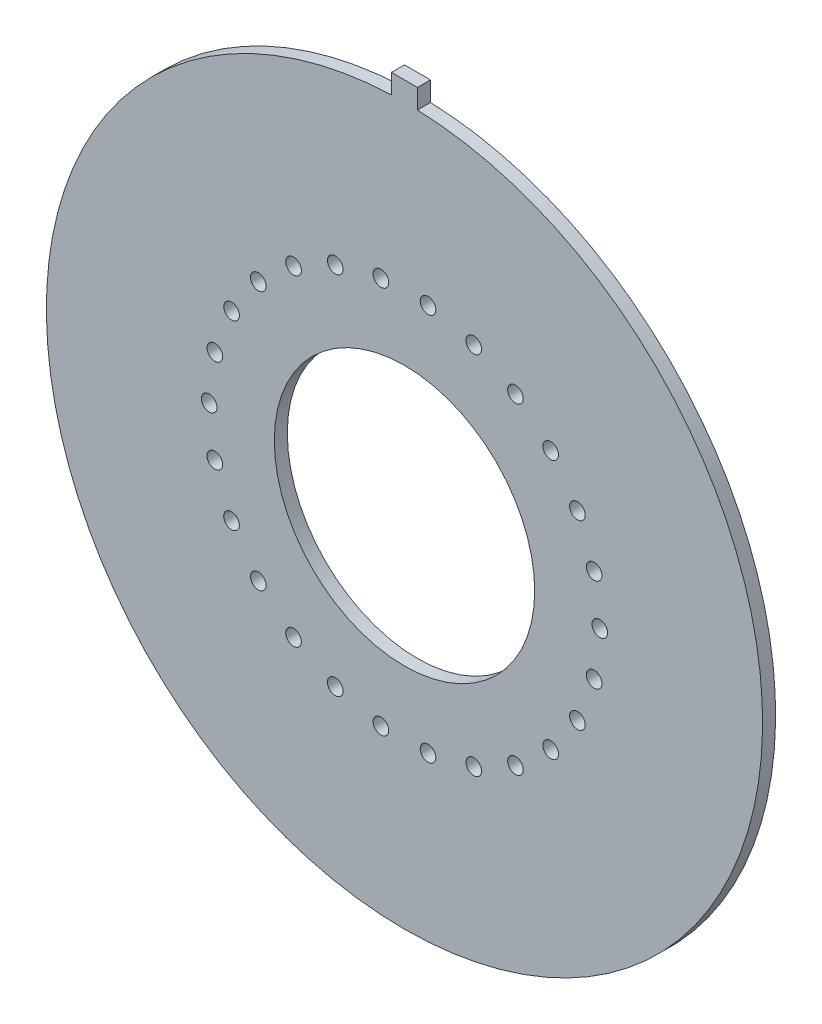
from build123d import *

# Parameters (mm, degrees)
PCB_DIMENSION_R     = 0.6
PCB_DIMENSION_R_2   = 10
BOSS_EXTRUDE1_DEPTH = 1


with BuildPart() as part:
    # PCB dimension → Boss-Extrude1 (new body)
    with BuildSketch(Plane.XY):
        with BuildLine():
            Line((-1, 27.481812167), (-1, 28.981812167))
            Line((-1, 28.981812167), (1, 28.981812167))
            Line((1, 28.981812167), (1, 27.481812167))
            ThreePointArc((1, 27.481812167), (0, -27.5), (-1, 27.481812167))
        make_face()
        with Locations((15, 0)):
            Circle(PCB_DIMENSION_R, mode=Mode.SUBTRACT)
        with Locations((14.564127261, -3.589734964)):
            Circle(PCB_DIMENSION_R, mode=Mode.SUBTRACT)
        with Locations((13.281840385, -6.970847581)):
            Circle(PCB_DIMENSION_R, mode=Mode.SUBTRACT)
        with Locations((11.227661223, -9.946839874)):
            Circle(PCB_DIMENSION_R, mode=Mode.SUBTRACT)
        with Locations((8.520971201, -12.344757988)):
            Circle(PCB_DIMENSION_R, mode=Mode.SUBTRACT)
        with Locations((5.319073306, -14.02524364)):
            Circle(PCB_DIMENSION_R, mode=Mode.SUBTRACT)
        with Locations((1.808050204, -14.890633111)):
            Circle(PCB_DIMENSION_R, mode=Mode.SUBTRACT)
        with Locations((-1.808050204, -14.890633111)):
            Circle(PCB_DIMENSION_R, mode=Mode.SUBTRACT)
        with Locations((-5.319073306, -14.02524364)):
            Circle(PCB_DIMENSION_R, mode=Mode.SUBTRACT)
        with Locations((-8.520971201, -12.344757988)):
            Circle(PCB_DIMENSION_R, mode=Mode.SUBTRACT)
        with Locations((-11.227661223, -9.946839874)):
            Circle(PCB_DIMENSION_R, mode=Mode.SUBTRACT)
        with Locations((-13.281840385, -6.970847581)):
            Circle(PCB_DIMENSION_R, mode=Mode.SUBTRACT)
        with Locations((-14.564127261, -3.589734964)):
            Circle(PCB_DIMENSION_R, mode=Mode.SUBTRACT)
        with Locations((-15, 0)):
            Circle(PCB_DIMENSION_R, mode=Mode.SUBTRACT)
        with Locations((-14.564127261, 3.589734964)):
            Circle(PCB_DIMENSION_R, mode=Mode.SUBTRACT)
        with Locations((-13.281840385, 6.970847581)):
            Circle(PCB_DIMENSION_R, mode=Mode.SUBTRACT)
        with Locations((-11.227661223, 9.946839874)):
            Circle(PCB_DIMENSION_R, mode=Mode.SUBTRACT)
        with Locations((-8.520971201, 12.344757988)):
            Circle(PCB_DIMENSION_R, mode=Mode.SUBTRACT)
        with Locations((-5.319073306, 14.02524364)):
            Circle(PCB_DIMENSION_R, mode=Mode.SUBTRACT)
        with Locations((-1.808050204, 14.890633111)):
            Circle(PCB_DIMENSION_R, mode=Mode.SUBTRACT)
        with Locations((1.808050204, 14.890633111)):
            Circle(PCB_DIMENSION_R, mode=Mode.SUBTRACT)
        with Locations((5.319073306, 14.02524364)):
            Circle(PCB_DIMENSION_R, mode=Mode.SUBTRACT)
        with Locations((8.520971201, 12.344757988)):
            Circle(PCB_DIMENSION_R, mode=Mode.SUBTRACT)
        with Locations((11.227661223, 9.946839874)):
            Circle(PCB_DIMENSION_R, mode=Mode.SUBTRACT)
        with Locations((13.281840385, 6.970847581)):
            Circle(PCB_DIMENSION_R, mode=Mode.SUBTRACT)
        with Locations((14.564127261, 3.589734964)):
            Circle(PCB_DIMENSION_R, mode=Mode.SUBTRACT)
        Circle(PCB_DIMENSION_R_2, mode=Mode.SUBTRACT)
    extrude(amount=BOSS_EXTRUDE1_DEPTH)


solid = part.part
